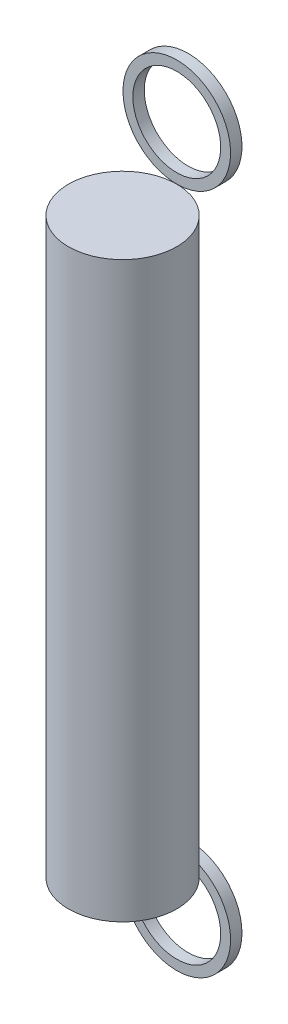
from build123d import *

# Parameters (mm, degrees)
SKETCH1_R             = 3.425
BOSS_EXTRUDE1_DEPTH   = 36.25
SKETCH2_R             = 3.4
SKETCH2_R_2           = 2.775
BOSS_EXTRUDE2_DEPTH   = 0.72
BOSS_EXTRUDE2_2_DEPTH = 0.72


with BuildPart() as part:
    # Sketch1 → Boss-Extrude1 (new body)
    with BuildSketch(Plane(origin=(0, 0, 0), x_dir=(1, 0, 0), z_dir=(0, 1, 0))):
        Circle(SKETCH1_R)
    extrude(amount=BOSS_EXTRUDE1_DEPTH)


with BuildPart() as body_2:
    # Sketch2 → Boss-Extrude2 (new body)
    with BuildSketch(Plane(origin=(0, 0, -3.425), x_dir=(-1, 0, 0), z_dir=(0, 0, -1))):
        with Locations((0, 39.65)):
            Circle(SKETCH2_R)
        with Locations((0, 39.65)):
            Circle(SKETCH2_R_2, mode=Mode.SUBTRACT)
    extrude(amount=BOSS_EXTRUDE2_DEPTH)


with BuildPart() as body_3:
    # Sketch2 → Boss-Extrude2 2 (new body)
    with BuildSketch(Plane(origin=(0, 0, -3.425), x_dir=(-1, 0, 0), z_dir=(0, 0, -1))):
        with Locations((0, -3.4)):
            Circle(SKETCH2_R)
        with Locations((0, -3.4)):
            Circle(SKETCH2_R_2, mode=Mode.SUBTRACT)
    extrude(amount=BOSS_EXTRUDE2_2_DEPTH)


solid = Compound([part.part, body_2.part, body_3.part])
